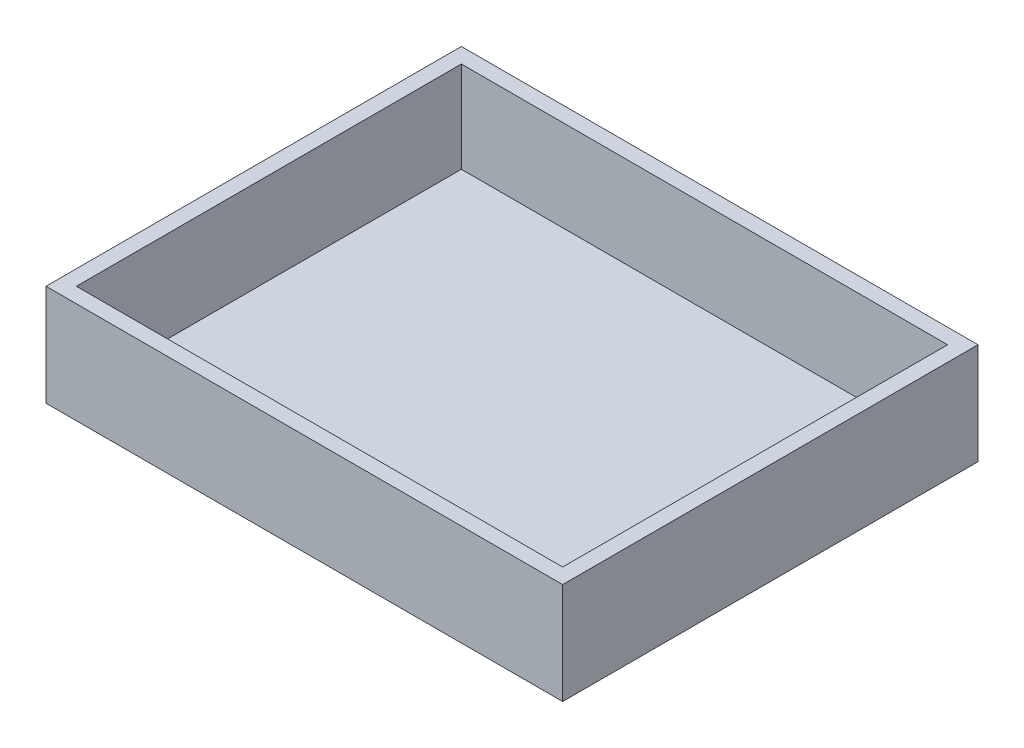
from build123d import *

# Parameters (mm, degrees)
SKETCH1_W           = 51
SKETCH1_H           = 41
SKETCH1_W_2         = 48
SKETCH1_H_2         = 38
BOSS_EXTRUDE1_DEPTH = 1
SKETCH1_3_W         = 51
SKETCH1_3_H         = 41
SKETCH1_3_W_2       = 48
SKETCH1_3_H_2       = 38
BOSS_EXTRUDE2_DEPTH = 10


with BuildPart() as part:
    # Sketch1 → Boss-Extrude1 (new body)
    with BuildSketch(Plane(origin=(0, 0, 0), x_dir=(1, 0, 0), z_dir=(0, 1, 0))):
        Rectangle(SKETCH1_W, SKETCH1_H)
        Rectangle(SKETCH1_W_2, SKETCH1_H_2, mode=Mode.SUBTRACT)
        Rectangle(SKETCH1_W_2, SKETCH1_H_2)
    extrude(amount=BOSS_EXTRUDE1_DEPTH)

    # Sketch1_3 → Boss-Extrude2 (add)
    with BuildSketch(Plane(origin=(0, 0, 0), x_dir=(1, 0, 0), z_dir=(0, 1, 0))):
        Rectangle(SKETCH1_3_W, SKETCH1_3_H)
        Rectangle(SKETCH1_3_W_2, SKETCH1_3_H_2, mode=Mode.SUBTRACT)
    extrude(amount=BOSS_EXTRUDE2_DEPTH)


solid = part.part
